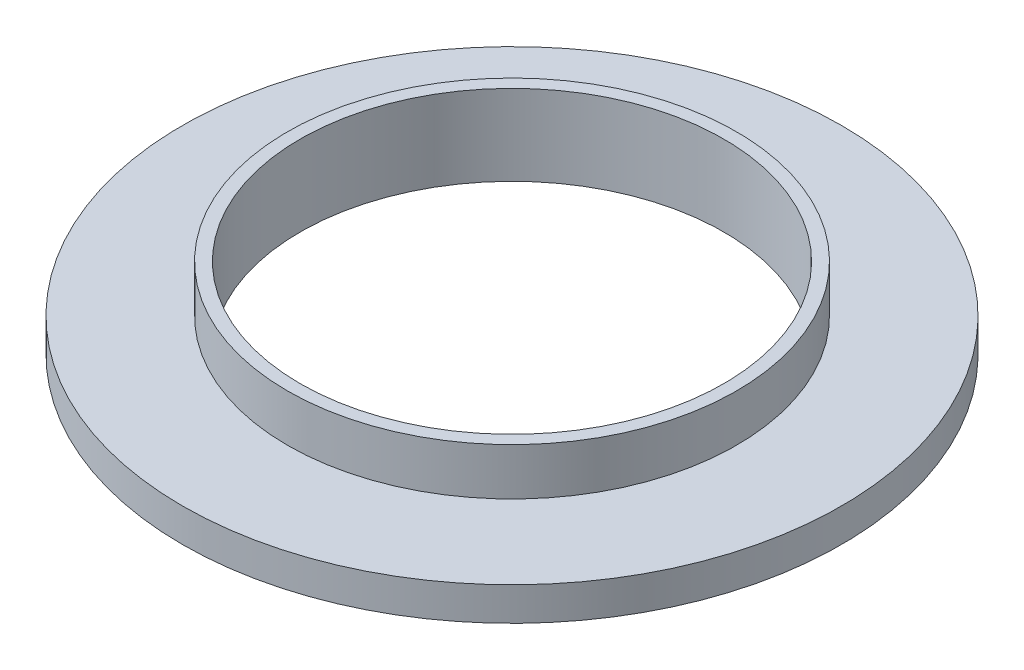
from build123d import *

# Parameters (mm, degrees)
SKETCH1_R           = 14
SKETCH1_R_2         = 9
BOSS_EXTRUDE1_DEPTH = 1.42
SKETCH2_R           = 9.5377
SKETCH2_R_2         = 9
BOSS_EXTRUDE2_DEPTH = 2


with BuildPart() as part:
    # Sketch1 → Boss-Extrude1 (new body)
    with BuildSketch(Plane(origin=(0, 0, 0), x_dir=(1, 0, 0), z_dir=(0, 1, 0))):
        Circle(SKETCH1_R)
        Circle(SKETCH1_R_2, mode=Mode.SUBTRACT)
    extrude(amount=BOSS_EXTRUDE1_DEPTH)

    # Sketch2 → Boss-Extrude2 (add)
    with BuildSketch(Plane(origin=(0, 1.42, 0), x_dir=(1, 0, 0), z_dir=(0, 1, 0))):
        Circle(SKETCH2_R)
        Circle(SKETCH2_R_2, mode=Mode.SUBTRACT)
    extrude(amount=BOSS_EXTRUDE2_DEPTH)


solid = part.part
